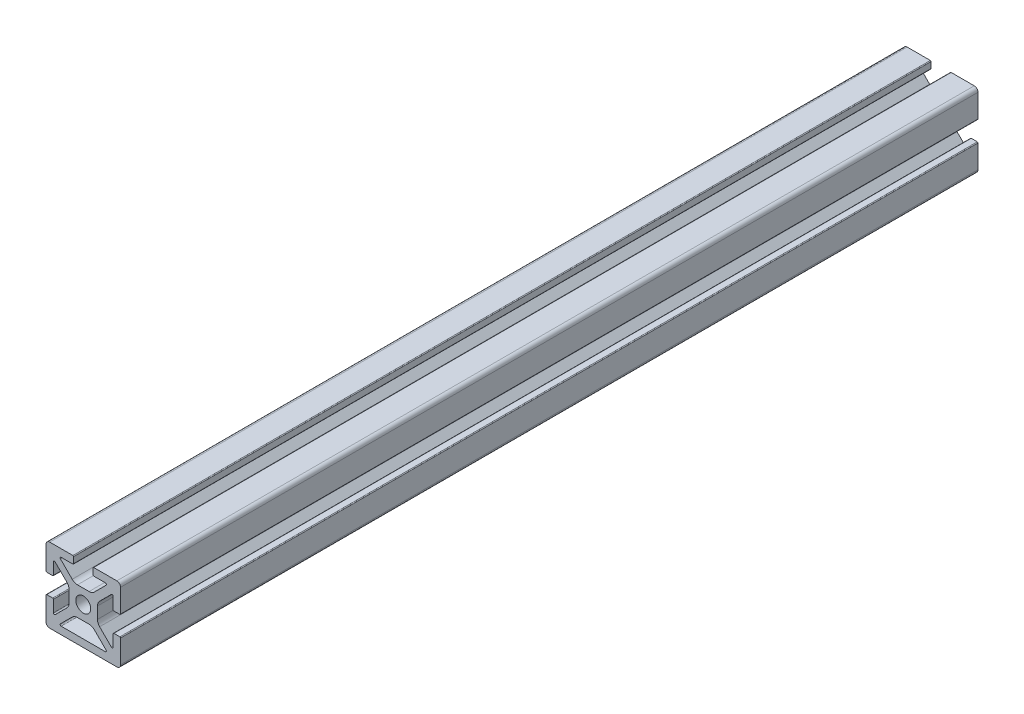
from build123d import *

# Parameters (mm, degrees)
BOSS_EXTRUDE1_DEPTH = 146.05
FILLET2_R           = 0.254
FILLET1_R           = 1.27
SKETCH5_W           = 7.112
SKETCH5_H           = 2.54
BOSS_EXTRUDE2_DEPTH = 292.1


with BuildPart() as part:
    # Sketch3 → Boss-Extrude1 (new body, symmetric)
    with BuildSketch(Plane.XY):
        with BuildLine():
            Line((-12.7, 12.7), (-1.796051224, 1.796051224))
            ThreePointArc((-1.796051224, 1.796051224), (-0.972015918, 2.346654013), (0, 2.54))
            Line((0, 2.54), (0, 4.826))
            Line((0, 4.826), (-1.977846327, 4.826))
            ThreePointArc((-1.977846327, 4.826), (-2.949862246, 5.019345987), (-3.773897552, 5.569948776))
            Line((-3.773897552, 5.569948776), (-7.772528286, 9.56857951))
            ThreePointArc((-7.772528286, 9.56857951), (-7.847628361, 9.946133082), (-7.527553898, 10.16))
            Line((-7.527553898, 10.16), (-3.302, 10.16))
            Line((-3.302, 10.16), (-3.302, 12.7))
            Line((-3.302, 12.7), (-12.7, 12.7))
        make_face()
    extrude(amount=BOSS_EXTRUDE1_DEPTH, both=True)

    # Fillet2
    fillet2_edges = [part.edges().sort_by_distance(p)[0] for p in [
        (-3.302, 12.7, 0),
        (-3.302, 10.16, 0),
    ]]
    fillet(fillet2_edges, radius=FILLET2_R)

    # Mirror1: part across plane


with BuildPart() as part_1:
    add(part.part)
    add(part.part.mirror(Plane(origin=(0, 0, 146.05), x_dir=(0, 0, 1), z_dir=(0.707106781, 0.707106781, 0))))

    # Fillet1
    fillet1_edges = [part_1.edges().sort_by_distance(p)[0] for p in [
        (-12.7, 12.7, 0),
    ]]
    fillet(fillet1_edges, radius=FILLET1_R)

    # Mirror2: part across plane


with BuildPart() as part_2:
    add(part_1.part)
    add(part_1.part.mirror(Plane(origin=(0, 0, 146.05), x_dir=(0, 0, 1), z_dir=(0, 1, 0))))

    # Mirror5: part across plane


with BuildPart() as part_3:
    add(part_2.part)
    add(part_2.part.mirror(Plane(origin=(0, 0, 146.05), x_dir=(0, 0, 1), z_dir=(-1, 0, 0))))

    # Sketch5 → Boss-Extrude2 (add, through all)
    with BuildSketch(Plane.XY.offset(146.05)):
        with Locations((0, -11.43)):
            Rectangle(SKETCH5_W, SKETCH5_H)
    extrude(amount=-BOSS_EXTRUDE2_DEPTH)


solid = part_3.part
